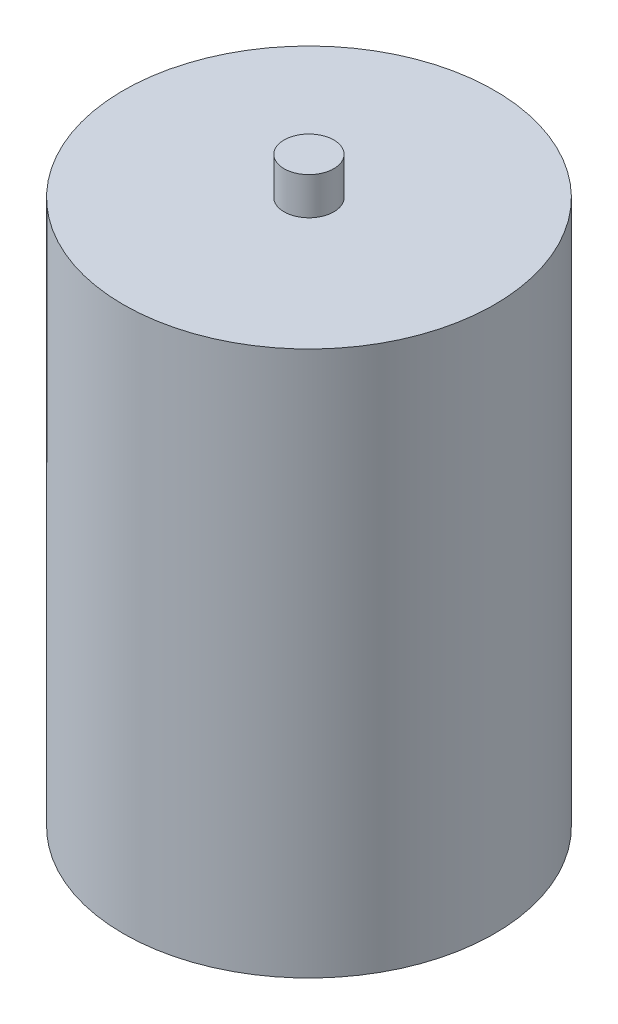
from build123d import *

# Parameters (mm, degrees)
SKETCH1_R           = 125.984
BOSS_EXTRUDE1_DEPTH = 369.824
SKETCH2_R           = 16.891
BOSS_EXTRUDE2_DEPTH = 25.4


with BuildPart() as part:
    # Sketch1 → Boss-Extrude1 (new body)
    with BuildSketch(Plane(origin=(0, 0, 0), x_dir=(1, 0, 0), z_dir=(0, 1, 0))):
        Circle(SKETCH1_R)
    extrude(amount=BOSS_EXTRUDE1_DEPTH)

    # Sketch2 → Boss-Extrude2 (add)
    with BuildSketch(Plane(origin=(0, 369.824, 0), x_dir=(1, 0, 0), z_dir=(0, 1, 0))):
        Circle(SKETCH2_R)
    extrude(amount=BOSS_EXTRUDE2_DEPTH)


solid = part.part
